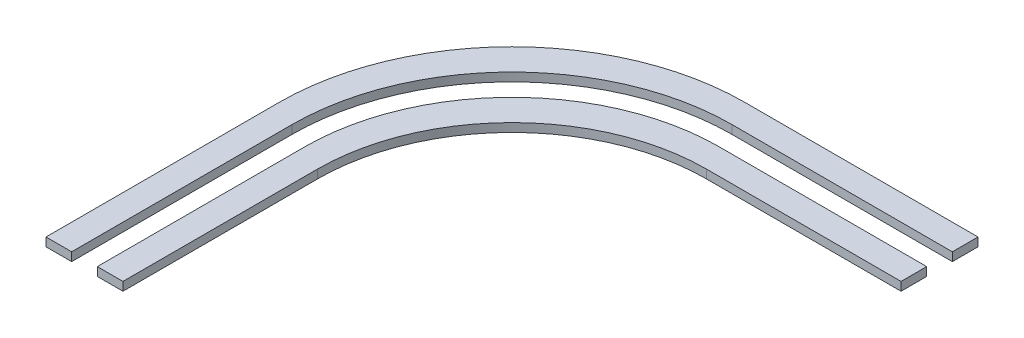
from build123d import *

# Parameters (mm, degrees)
BOSS_EXTRUDE1_DEPTH   = 10
BOSS_EXTRUDE1_2_DEPTH = 10


with BuildPart() as part:
    # Sketch2 → Boss-Extrude1 (new body)
    with BuildSketch(Plane(origin=(0, 0, 0), x_dir=(1, 0, 0), z_dir=(0, 1, 0))):
        with BuildLine():
            Line((455, 272.5), (455, 0))
            Line((455, 0), (485, 0))
            Line((485, 0), (485, 257.5))
            ThreePointArc((485, 257.5), (560.420003844, 439.579996156), (742.5, 515))
            Line((742.5, 515), (1000, 515))
            Line((1000, 515), (1000, 545))
            Line((1000, 545), (727.5, 545))
            ThreePointArc((727.5, 545), (534.813402127, 465.186597873), (455, 272.5))
        make_face()
    extrude(amount=BOSS_EXTRUDE1_DEPTH)


with BuildPart() as body_2:
    # Sketch2 → Boss-Extrude1 2 (new body)
    with BuildSketch(Plane(origin=(0, 0, 0), x_dir=(1, 0, 0), z_dir=(0, 1, 0))):
        with BuildLine():
            Line((515, 242.5), (515, 0))
            Line((515, 0), (545, 0))
            Line((545, 0), (545, 227.5))
            ThreePointArc((545, 227.5), (611.63320728, 388.36679272), (772.5, 455))
            Line((772.5, 455), (1000, 455))
            Line((1000, 455), (1000, 485))
            Line((1000, 485), (757.5, 485))
            ThreePointArc((757.5, 485), (586.026605562, 413.973394438), (515, 242.5))
        make_face()
    extrude(amount=BOSS_EXTRUDE1_2_DEPTH)


solid = Compound([part.part, body_2.part])
